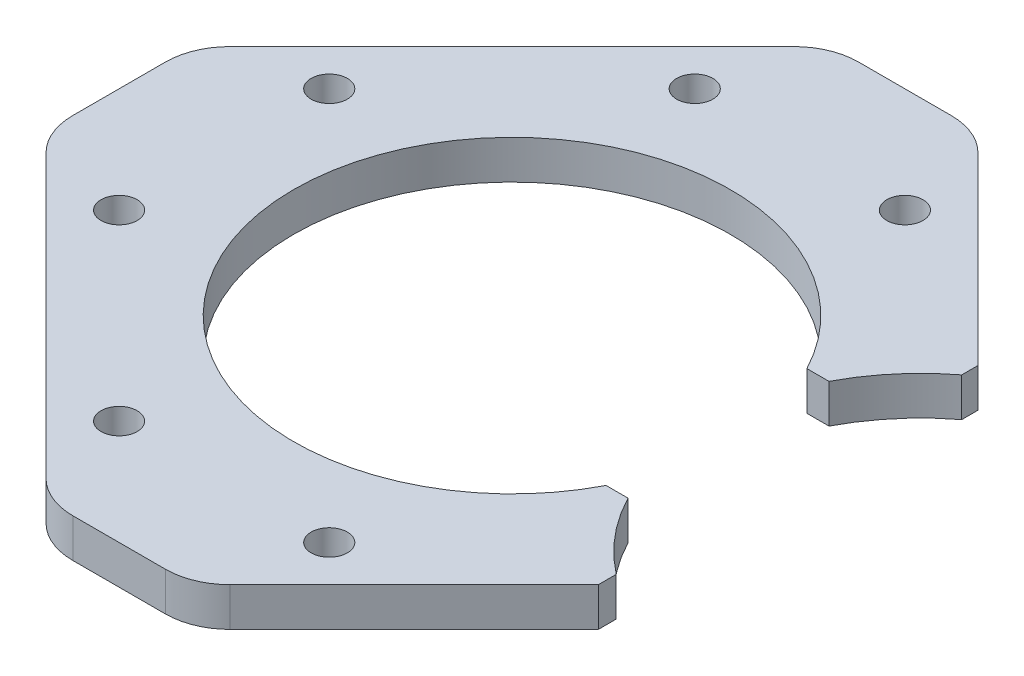
from build123d import *

# Parameters (mm, degrees)
SKETCH1_R           = 1.4
BOSS_EXTRUDE1_DEPTH = 3


with BuildPart() as part:
    # Sketch1 → Boss-Extrude1 (new body)
    with BuildSketch(Plane(origin=(0, 0, 0), x_dir=(1, 0, 0), z_dir=(0, 1, 0))):
        with BuildLine():
            Line((25.742531042, 14.690082128), (11.491487674, 28.941125497))
            ThreePointArc((11.491487674, 28.941125497), (9.869370929, 30.024989254), (7.955953768, 30.405591591))
            Line((7.955953768, 30.405591591), (0.784380892, 30.405591591))
            ThreePointArc((0.784380892, 30.405591591), (-1.129036269, 30.024989254), (-2.751153014, 28.941125497))
            Line((-2.751153014, 28.941125497), (-24.570958167, 7.121320344))
            ThreePointArc((-24.570958167, 7.121320344), (-25.654821924, 5.499203599), (-26.035424261, 3.585786438))
            Line((-26.035424261, 3.585786438), (-26.035424261, -3.585786438))
            ThreePointArc((-26.035424261, -3.585786438), (-25.654821924, -5.499203599), (-24.570958167, -7.121320344))
            Line((-24.570958167, -7.121320344), (-2.751153014, -28.941125497))
            ThreePointArc((-2.751153014, -28.941125497), (-1.129036269, -30.024989254), (0.784380892, -30.405591591))
            Line((0.784380892, -30.405591591), (7.955953768, -30.405591591))
            ThreePointArc((7.955953768, -30.405591591), (9.869370929, -30.024989254), (11.491487674, -28.941125497))
            Line((11.491487674, -28.941125497), (25.742531042, -14.690082128))
            Line((25.742531042, -14.690082128), (25.742531042, -13.305049063))
            ThreePointArc((25.742531042, -13.305049063), (23.11272458, -10.777668219), (21.090366856, -7.742276119))
            Line((21.090366856, -7.742276119), (19.392389552, -7.742276119))
            ThreePointArc((19.392389552, -7.742276119), (-12.529702293, -0.066383131), (19.331103203, 7.860050751))
            Line((19.331103203, 7.860050751), (21.039064127, 7.860050751))
            ThreePointArc((21.039064127, 7.860050751), (23.086785029, 10.90224193), (25.742531042, 13.431095658))
            Line((25.742531042, 13.431095658), (25.742531042, 14.690082128))
        make_face()
        with Locations((12.501895314, -22.273863607)):
            Circle(SKETCH1_R, mode=Mode.SUBTRACT)
        with Locations((-3.761560654, -22.273863607)):
            Circle(SKETCH1_R, mode=Mode.SUBTRACT)
        with Locations((-17.903696277, -8.131727984)):
            Circle(SKETCH1_R, mode=Mode.SUBTRACT)
        with Locations((-17.903696277, 8.131727984)):
            Circle(SKETCH1_R, mode=Mode.SUBTRACT)
        with Locations((-3.761560654, 22.273863607)):
            Circle(SKETCH1_R, mode=Mode.SUBTRACT)
        with Locations((12.501895314, 22.273863607)):
            Circle(SKETCH1_R, mode=Mode.SUBTRACT)
    extrude(amount=BOSS_EXTRUDE1_DEPTH)


solid = part.part
